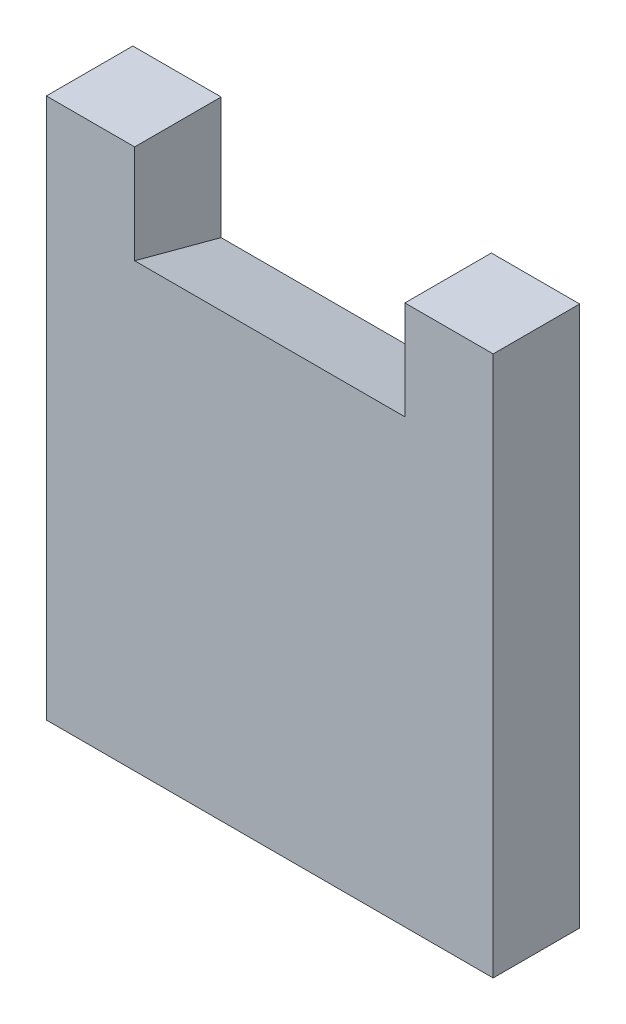
from build123d import *

# Parameters (mm, degrees)
EXTRUDE_1_DEPTH = 9.6
DRAFT_5_ANGLE   = -15


with BuildPart() as part:
    # 草图1 → 凸台-拉伸1 (new body)
    with BuildSketch(Plane.XY):
        Polygon((9.8, 0), (0, 0), (0, -60), (49.6, -60), (49.6, 0), (39.8, 0), (39.8, -10.95), (9.8, -10.95), align=None)
    extrude(amount=EXTRUDE_1_DEPTH)

    # 拔模5
    draft_5_faces = [part.faces().sort_by_distance(p)[0] for p in [
        (24.8, -10.95, 4.8),
    ]]
    draft(draft_5_faces, Plane.XY.offset(9.6), DRAFT_5_ANGLE)


solid = part.part
